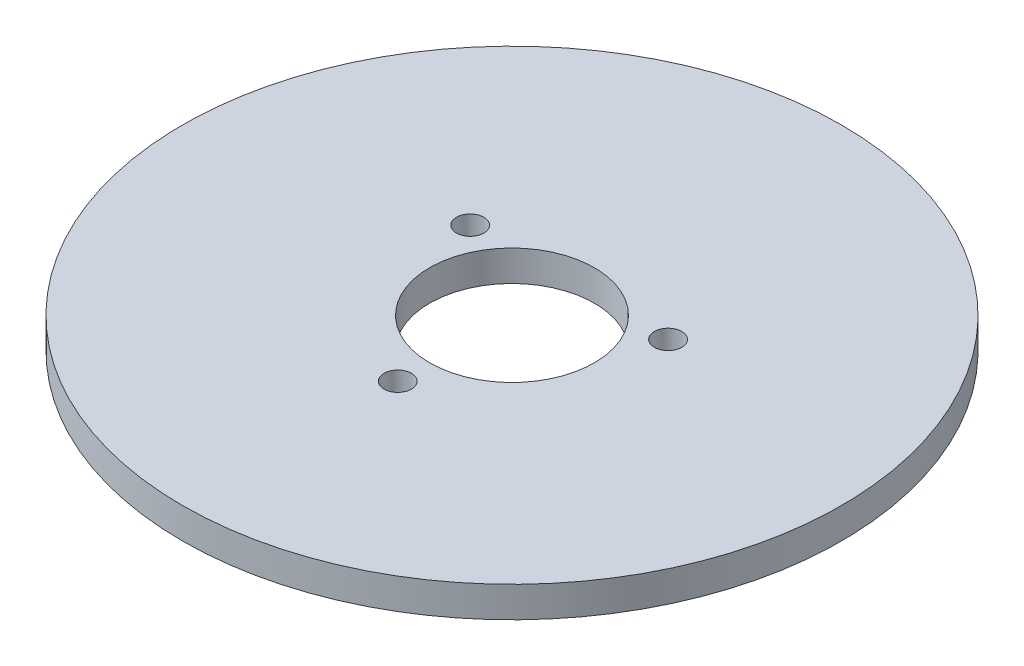
from build123d import *

# Parameters (mm, degrees)
BOSS_EXTRUDE1_DEPTH      = 0.889
BOSS_EXTRUDE1_DEPTH_BACK = 0.889
SKETCH2_R                = 19.05
SKETCH4_R                = 4.7625
CUT_EXTRUDE1_DEPTH       = 27.999375622
SKETCH5_R                = 0.79375
CUT_EXTRUDE2_DEPTH       = 27.999375622


with BuildPart() as part:
    # Sketch2 → Boss-Extrude1 (new, two sides: drawn at the far end of the back side and taken through both)
    with BuildSketch(Plane(origin=(0, 0, 0), x_dir=(1, 0, 0), z_dir=(0, 1, 0)).offset(-BOSS_EXTRUDE1_DEPTH_BACK)):
        Circle(SKETCH2_R)
    extrude(amount=BOSS_EXTRUDE1_DEPTH + BOSS_EXTRUDE1_DEPTH_BACK)

    # Sketch4 → Cut-Extrude1 (cut, through all)
    with BuildSketch(Plane(origin=(0, 0.889, 0), x_dir=(1, 0, 0), z_dir=(0, 1, 0))):
        Circle(SKETCH4_R)
    extrude(amount=-CUT_EXTRUDE1_DEPTH, mode=Mode.SUBTRACT)

    # Sketch5 → Cut-Extrude2 (cut, through all)
    with BuildSketch(Plane.XZ.offset(0.889)):
        with Locations((0, 6.604)):
            Circle(SKETCH5_R)
        with Locations((5.719231767, -3.302)):
            Circle(SKETCH5_R)
        with Locations((-5.719231767, -3.302)):
            Circle(SKETCH5_R)
    extrude(amount=-CUT_EXTRUDE2_DEPTH, mode=Mode.SUBTRACT)


solid = part.part
